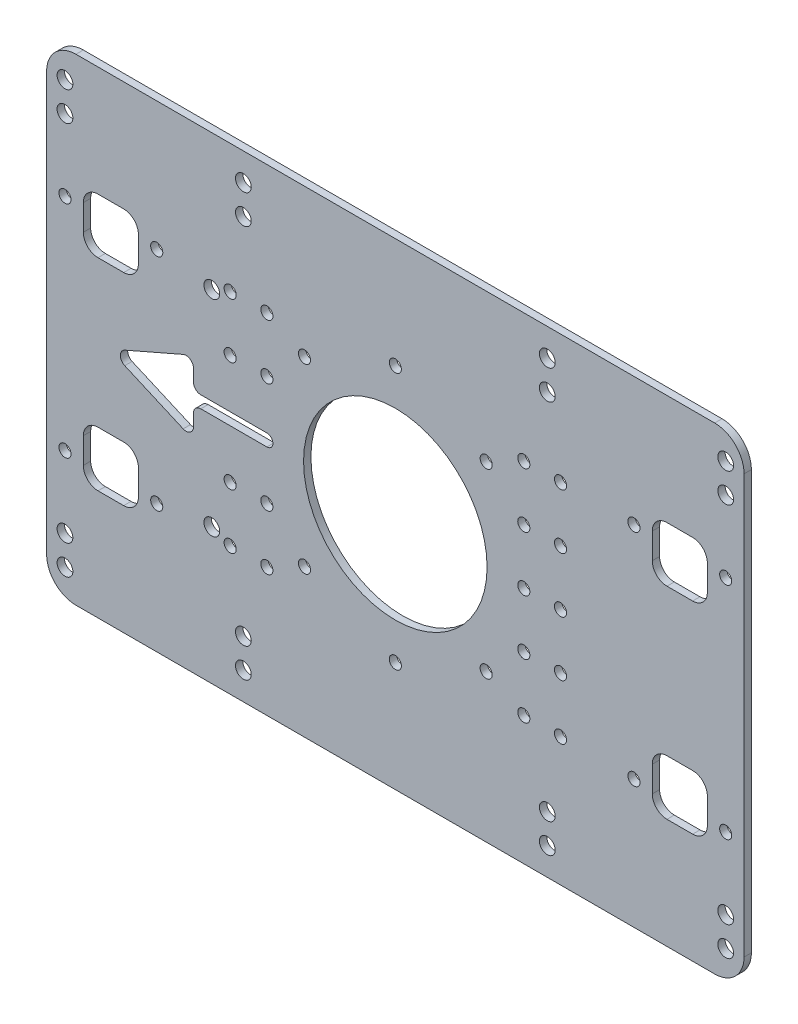
from build123d import *

# Parameters (mm, degrees)
SKETCH_1_W          = 190
SKETCH_1_H          = 130
SKETCH_1_R          = 2.15
EXTRUDE_1_DEPTH     = 2
FILLET_1_R          = 8
SKETCH_2_R          = 25
CUT_EXTRUDE_1_DEPTH = 10
CUT_EXTRUDE_2_DEPTH = 10
FILLET_2_R          = 2
SKETCH_5_R          = 1.65
CUT_EXTRUDE_5_DEPTH = 3.3
SKETCH_6_R          = 1.65
CUT_EXTRUDE_6_DEPTH = 3.3
SKETCH_7_R          = 2.15
CUT_EXTRUDE_7_DEPTH = 3.3


with BuildPart() as part:
    # 草图1 → 凸台-拉伸1 (new body)
    with BuildSketch(Plane.XY):
        with Locations((95, 65)):
            Rectangle(SKETCH_1_W, SKETCH_1_H)
        with Locations((136.4, 7.5)):
            Circle(SKETCH_1_R, mode=Mode.SUBTRACT)
        with Locations((185, 15.5)):
            Circle(SKETCH_1_R, mode=Mode.SUBTRACT)
        with Locations((185, 114.5)):
            Circle(SKETCH_1_R, mode=Mode.SUBTRACT)
        with Locations((136.4, 114.5)):
            Circle(SKETCH_1_R, mode=Mode.SUBTRACT)
        with Locations((136.4, 122.5)):
            Circle(SKETCH_1_R, mode=Mode.SUBTRACT)
        with Locations((185, 122.5)):
            Circle(SKETCH_1_R, mode=Mode.SUBTRACT)
        with Locations((5, 122.5)):
            Circle(SKETCH_1_R, mode=Mode.SUBTRACT)
        with Locations((5, 114.5)):
            Circle(SKETCH_1_R, mode=Mode.SUBTRACT)
        with Locations((5, 15.5)):
            Circle(SKETCH_1_R, mode=Mode.SUBTRACT)
        with Locations((53.6, 15.5)):
            Circle(SKETCH_1_R, mode=Mode.SUBTRACT)
        with Locations((53.6, 7.5)):
            Circle(SKETCH_1_R, mode=Mode.SUBTRACT)
        with Locations((5, 7.5)):
            Circle(SKETCH_1_R, mode=Mode.SUBTRACT)
        with Locations((53.6, 122.5)):
            Circle(SKETCH_1_R, mode=Mode.SUBTRACT)
        with Locations((53.6, 114.5)):
            Circle(SKETCH_1_R, mode=Mode.SUBTRACT)
        with Locations((185, 7.5)):
            Circle(SKETCH_1_R, mode=Mode.SUBTRACT)
        with Locations((136.4, 15.5)):
            Circle(SKETCH_1_R, mode=Mode.SUBTRACT)
    extrude(amount=EXTRUDE_1_DEPTH)

    # 圆角1
    fillet_1_edges = [part.edges().sort_by_distance(p)[0] for p in [
        (0, 0, 1),
        (0, 130, 1),
        (190, 130, 1),
        (190, 0, 1),
    ]]
    fillet(fillet_1_edges, radius=FILLET_1_R)

    # 草图2 → 切除-拉伸1 (cut)
    with BuildSketch(Plane(origin=(0, 0, 0), x_dir=(-1, 0, 0), z_dir=(0, 0, -1))):
        with Locations((-95, 65)):
            Circle(SKETCH_2_R)
        with BuildLine():
            Line((-21, 85), (-14, 85))
            ThreePointArc((-14, 85), (-11.171572875, 86.171572875), (-10, 89))
            Line((-10, 89), (-10, 96))
            ThreePointArc((-10, 96), (-11.171572875, 98.828427125), (-14, 100))
            Line((-14, 100), (-21, 100))
            ThreePointArc((-21, 100), (-23.828427125, 98.828427125), (-25, 96))
            Line((-25, 96), (-25, 89))
            ThreePointArc((-25, 89), (-23.828427125, 86.171572875), (-21, 85))
        make_face()
        with BuildLine():
            Line((-21, 30), (-14, 30))
            ThreePointArc((-14, 30), (-11.171572875, 31.171572875), (-10, 34))
            Line((-10, 34), (-10, 41))
            ThreePointArc((-10, 41), (-11.171572875, 43.828427125), (-14, 45))
            Line((-14, 45), (-21, 45))
            ThreePointArc((-21, 45), (-23.828427125, 43.828427125), (-25, 41))
            Line((-25, 41), (-25, 34))
            ThreePointArc((-25, 34), (-23.828427125, 31.171572875), (-21, 30))
        make_face()
        with BuildLine():
            Line((-165, 96), (-165, 89))
            ThreePointArc((-165, 89), (-166.171572875, 86.171572875), (-169, 85))
            Line((-169, 85), (-176, 85))
            ThreePointArc((-176, 85), (-178.828427125, 86.171572875), (-180, 89))
            Line((-180, 89), (-180, 96))
            ThreePointArc((-180, 96), (-178.828427125, 98.828427125), (-176, 100))
            Line((-176, 100), (-169, 100))
            ThreePointArc((-169, 100), (-166.171572875, 98.828427125), (-165, 96))
        make_face()
        with BuildLine():
            Line((-169, 45), (-176, 45))
            ThreePointArc((-176, 45), (-178.828427125, 43.828427125), (-180, 41))
            Line((-180, 41), (-180, 34))
            ThreePointArc((-180, 34), (-178.828427125, 31.171572875), (-176, 30))
            Line((-176, 30), (-169, 30))
            ThreePointArc((-169, 30), (-166.171572875, 31.171572875), (-165, 34))
            Line((-165, 34), (-165, 41))
            ThreePointArc((-165, 41), (-166.171572875, 43.828427125), (-169, 45))
        make_face()
    extrude(amount=-CUT_EXTRUDE_1_DEPTH, mode=Mode.SUBTRACT)

    # 草图4 → 切除-拉伸2 (cut)
    with BuildSketch(Plane(origin=(0, 0, 0), x_dir=(-1, 0, 0), z_dir=(0, 0, -1))):
        with BuildLine():
            Line((-40, 55), (-17.087121525, 65))
            Line((-17.087121525, 65), (-40, 75))
            Line((-40, 75), (-40, 66.65))
            Line((-40, 66.65), (-60, 66.65))
            ThreePointArc((-60, 66.65), (-61.65, 65), (-60, 63.35))
            Line((-60, 63.35), (-40, 63.35))
            Line((-40, 63.35), (-40, 55))
        make_face()
    extrude(amount=-CUT_EXTRUDE_2_DEPTH, mode=Mode.SUBTRACT)

    # 圆角2
    fillet_2_edges = [part.edges().sort_by_distance(p)[0] for p in [
        (40, 66.65, 1),
        (40, 75, 1),
        (17.087121525, 65, 1),
        (40, 55, 1),
        (40, 63.35, 1),
    ]]
    fillet(fillet_2_edges, radius=FILLET_2_R)

    # 草图5 → 切除-拉伸5 (cut)
    with BuildSketch(Plane(origin=(0, 0, 0), x_dir=(-1, 0, 0), z_dir=(0, 0, -1))):
        with Locations((-160, 35)):
            Circle(SKETCH_5_R)
        with Locations((-185, 95)):
            Circle(SKETCH_5_R)
        with Locations((-185, 35)):
            Circle(SKETCH_5_R)
        with Locations((-160, 95)):
            Circle(SKETCH_5_R)
    cut_extrude_5 = extrude(amount=-CUT_EXTRUDE_5_DEPTH, mode=Mode.SUBTRACT)

    # 草图6 → 切除-拉伸6 (cut)
    with BuildSketch(Plane(origin=(0, 0, 0), x_dir=(-1, 0, 0), z_dir=(0, 0, -1))):
        with Locations((-140, 35)):
            Circle(SKETCH_6_R)
        with Locations((-130, 35)):
            Circle(SKETCH_6_R)
        with Locations((-130, 50)):
            Circle(SKETCH_6_R)
        with Locations((-130, 65)):
            Circle(SKETCH_6_R)
        with Locations((-130, 80)):
            Circle(SKETCH_6_R)
        with Locations((-130, 95)):
            Circle(SKETCH_6_R)
        with Locations((-140, 50)):
            Circle(SKETCH_6_R)
        with Locations((-140, 65)):
            Circle(SKETCH_6_R)
        with Locations((-140, 80)):
            Circle(SKETCH_6_R)
        with Locations((-140, 95)):
            Circle(SKETCH_6_R)
        with Locations((-95, 30)):
            Circle(SKETCH_6_R)
        with Locations((-119.748737342, 40.251262658)):
            Circle(SKETCH_6_R)
        with Locations((-119.748737342, 89.748737342)):
            Circle(SKETCH_6_R)
        with Locations((-95, 100)):
            Circle(SKETCH_6_R)
        with Locations((-70.251262658, 89.748737342)):
            Circle(SKETCH_6_R)
        with Locations((-70.251262658, 40.251262658)):
            Circle(SKETCH_6_R)
    cut_extrude_6 = extrude(amount=-CUT_EXTRUDE_6_DEPTH, mode=Mode.SUBTRACT)

    # 镜向1: 切除-拉伸6 across plane
    add(cut_extrude_6.mirror(Plane.ZY.offset(-95)), mode=Mode.SUBTRACT)

    # 镜向2: 切除-拉伸5 across plane
    add(cut_extrude_5.mirror(Plane.ZY.offset(-95)), mode=Mode.SUBTRACT)

    # 草图7 → 切除-拉伸7 (cut)
    with BuildSketch(Plane.XY.offset(2)):
        with Locations((45, 37)):
            Circle(SKETCH_7_R)
        with Locations((45, 93)):
            Circle(SKETCH_7_R)
    extrude(amount=-CUT_EXTRUDE_7_DEPTH, mode=Mode.SUBTRACT)


solid = part.part
